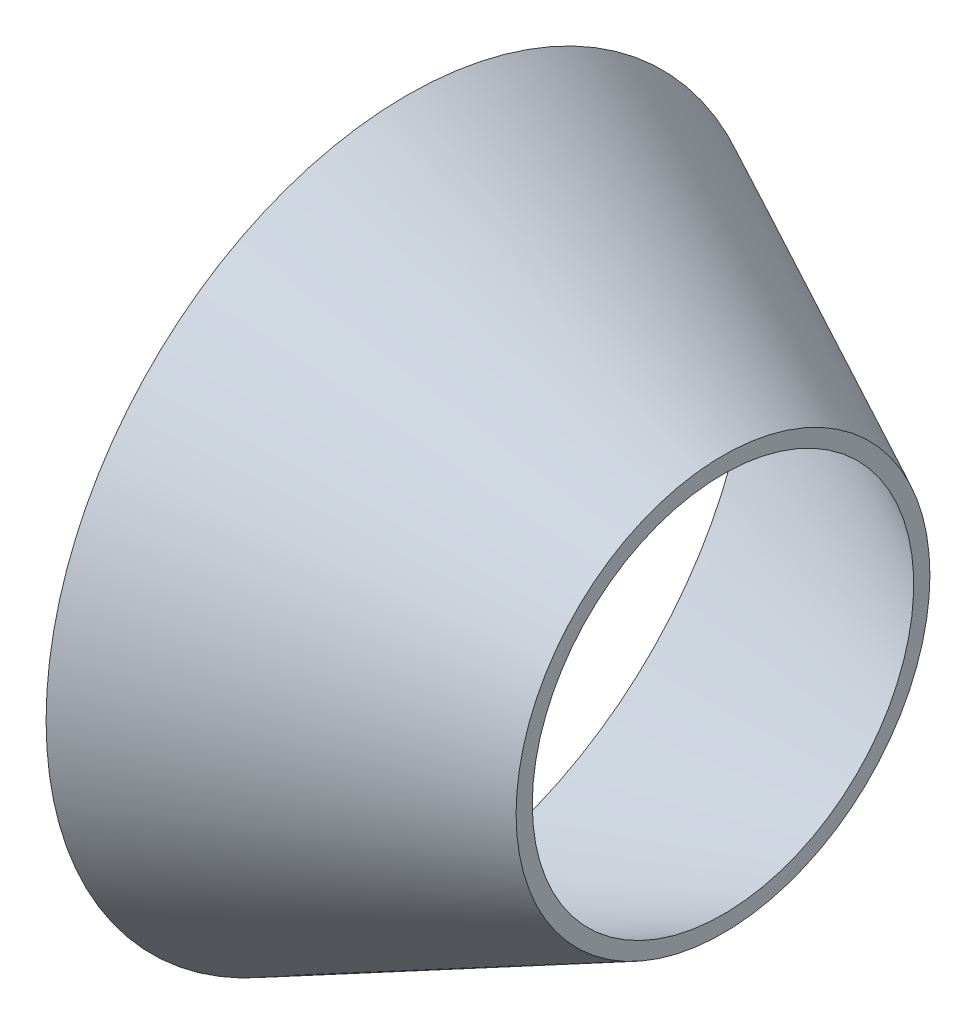
from build123d import *

# Parameters (mm, degrees)
BOSS_EXTRUDE2_REACH             = 1012.589
SKETCH2_RX                      = 10
SKETCH2_RY                      = 6
BOSS_EXTRUDE2_DIRECTION_2_DEPTH = 70


with BuildPart() as part:
    # Sketch1 → Revolve2 (revolve)
    with BuildSketch(Plane.XY):
        Polygon((-130.732282232, 261.929667421), (-130.732282232, 284.18170623), (-564.604342542, 495.79524931), (-564.604342542, 473.543210501), align=None)
    revolve(axis=Axis((-564.604342542, 0, 0), (1, 0, 0)))

    # Boss-Extrude2: up to this cone (the profile starts inside it)
    boss_extrude2_end = Plane(origin=(-375, 0, 0), z_dir=(-1, 0, 0)).offset(-826.926560762) * Cone(1e-06, 1181.939254622, 2423.334593281, align=(Align.CENTER, Align.CENTER, Align.MIN), mode=Mode.PRIVATE)
    # Sketch2 → Boss-Extrude2 (add, up to the surface)
    with BuildSketch(Plane(origin=(0, 180, 0), x_dir=(1, 0, 0), z_dir=(0, 1, 0)), mode=Mode.PRIVATE) as boss_extrude2_sk1:
        with Locations(Location((-195, 0), (0, 0, -90))):
            Ellipse(SKETCH2_RX, SKETCH2_RY)
    boss_extrude2_tool1 = extrude(boss_extrude2_sk1.sketch, amount=BOSS_EXTRUDE2_REACH, mode=Mode.PRIVATE) & boss_extrude2_end
    add(boss_extrude2_tool1.solids().sort_by_distance((-195, 180, 0))[0])
    # Sketch2 → Boss-Extrude2 (add, up to the surface)
    with BuildSketch(Plane(origin=(0, 180, 0), x_dir=(1, 0, 0), z_dir=(0, 1, 0)), mode=Mode.PRIVATE) as boss_extrude2_sk2:
        with Locations(Location((-315, 0), (0, 0, -90))):
            Ellipse(SKETCH2_RX, SKETCH2_RY)
    boss_extrude2_tool2 = extrude(boss_extrude2_sk2.sketch, amount=BOSS_EXTRUDE2_REACH, mode=Mode.PRIVATE) & boss_extrude2_end
    add(boss_extrude2_tool2.solids().sort_by_distance((-315, 180, 0))[0])
    # Sketch2 → Boss-Extrude2 (add, up to the surface)
    with BuildSketch(Plane(origin=(0, 180, 0), x_dir=(1, 0, 0), z_dir=(0, 1, 0)), mode=Mode.PRIVATE) as boss_extrude2_sk3:
        with Locations(Location((-455, 0), (0, 0, -90))):
            Ellipse(SKETCH2_RX, SKETCH2_RY)
    boss_extrude2_tool3 = extrude(boss_extrude2_sk3.sketch, amount=BOSS_EXTRUDE2_REACH, mode=Mode.PRIVATE) & boss_extrude2_end
    add(boss_extrude2_tool3.solids().sort_by_distance((-455, 180, 0))[0])
    # Sketch2 → Boss-Extrude2 (add, up to the surface)
    with BuildSketch(Plane(origin=(0, 180, 0), x_dir=(1, 0, 0), z_dir=(0, 1, 0)), mode=Mode.PRIVATE) as boss_extrude2_sk4:
        with Locations(Location((-555, 0), (0, 0, -90))):
            Ellipse(SKETCH2_RX, SKETCH2_RY)
    boss_extrude2_tool4 = extrude(boss_extrude2_sk4.sketch, amount=BOSS_EXTRUDE2_REACH, mode=Mode.PRIVATE) & boss_extrude2_end
    add(boss_extrude2_tool4.solids().sort_by_distance((-555, 180, 0))[0])

    # Sketch2 → Boss-Extrude2 direction 2 (add)
    with BuildSketch(Plane(origin=(0, 180, 0), x_dir=(1, 0, 0), z_dir=(0, 1, 0))):
        with Locations(Location((-195, 0), (0, 0, -90))):
            Ellipse(SKETCH2_RX, SKETCH2_RY)
        with Locations(Location((-315, 0), (0, 0, -90))):
            Ellipse(SKETCH2_RX, SKETCH2_RY)
        with Locations(Location((-455, 0), (0, 0, -90))):
            Ellipse(SKETCH2_RX, SKETCH2_RY)
        with Locations(Location((-555, 0), (0, 0, -90))):
            Ellipse(SKETCH2_RX, SKETCH2_RY)
    extrude(amount=-BOSS_EXTRUDE2_DIRECTION_2_DEPTH)

    # Sketch3 → Cut-Revolve1 (revolve, cut)
    with BuildSketch(Plane.XY):
        Polygon((-582.142013532, 344.888236952), (-582.142013532, 0), (62.909575816, -0.566881744), (62.909575816, 172.04718451), align=None)
    revolve(axis=Axis((-582.142013532, 0, 0), (0.9999996138413244, -0.0008788157952992667, 0)), mode=Mode.SUBTRACT)


solid = part.part
